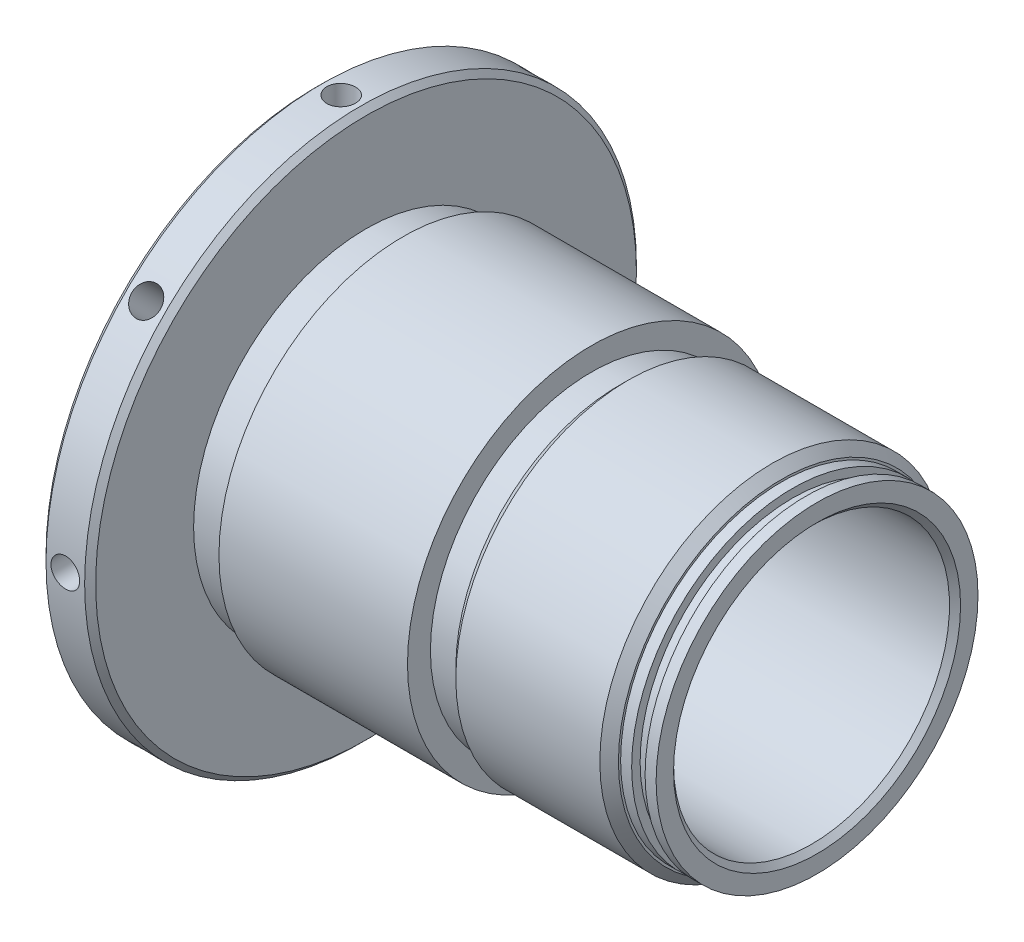
from build123d import *

# Parameters (mm, degrees)
CHAMFER1_SIZE      = 0.762
SKETCH3_W          = 6.858
SKETCH3_H          = 18.542
SKETCH5_W          = 5.08
SKETCH5_H          = 1.58115
CHAMFER3_SIZE      = 0.762
SKETCH6_R          = 1.9812
CUT_EXTRUDE2_DEPTH = 6.35
CHAMFER4_SIZE      = 1.2827
CIRPATTERN2_COUNT  = 8
SKETCH7_W          = 1.524
SKETCH7_H          = 0.4064
EXTRUDE1_DEPTH     = 0.0254


with BuildPart() as part:
    # Sketch1 → Revolve1 (revolve)
    with BuildSketch(Plane.XY, mode=Mode.PRIVATE) as revolve1_sk:
        Polygon((0, 19.558), (0, 25.39365), (62.2808, 25.39365), (62.2808, 19.05635), (22.09165, 19.05635), (20.828, 20.32), (17.78, 20.32), (17.018, 19.558), align=None)
    revolve(revolve1_sk.sketch.rotate(Axis((0, 0, 0), (1, 0, 0)), 90), axis=Axis((0, 0, 0), (1, 0, 0)))  # turned: the seam where the file's is

    # Sketch2 → Cut-Revolve1 (revolve, cut)
    with BuildSketch(Plane.XY, mode=Mode.PRIVATE) as cut_revolve1_sk:
        Polygon((31.115, 25.39365), (62.2808, 25.39365), (62.2808, 22.225), (60.7568, 22.225), (60.7568, 21.0566), (58.9026, 21.0566), (58.9026, 22.225), (57.3786, 22.225), (57.3786, 23.8125), (34.925, 23.8125), (34.925, 22.225), (31.115, 22.225), align=None)
    revolve(cut_revolve1_sk.sketch.rotate(Axis((0, 0, 0), (1, 0, 0)), 90), axis=Axis((0, 0, 0), (1, 0, 0)), mode=Mode.SUBTRACT)  # turned: the seam where the file's is

    # Chamfer1
    chamfer1_edges = [part.edges().sort_by_distance(p)[0] for p in [
        (62.2808, 0, -19.05635),
    ]]
    chamfer(chamfer1_edges, length=CHAMFER1_SIZE)

    # Sketch3 → Revolve2 (revolve)
    with BuildSketch(Plane.XY, mode=Mode.PRIVATE) as revolve2_sk:
        with Locations((-3.429, 28.829)):
            Rectangle(SKETCH3_W, SKETCH3_H)
    revolve(revolve2_sk.sketch.rotate(Axis((0, 0, 0), (-1, 0, 0)), 270), axis=Axis((0, 0, 0), (-1, 0, 0)))  # turned: the seam where the file's is

    # Sketch5 → Cut-Revolve2 (revolve, cut)
    with BuildSketch(Plane.XY, mode=Mode.PRIVATE) as cut_revolve2_sk:
        with Locations((2.54, 24.603075)):
            Rectangle(SKETCH5_W, SKETCH5_H)
    revolve(cut_revolve2_sk.sketch.rotate(Axis((23.353313309, 0, 0), (1, 0, 0)), 90), axis=Axis((23.353313309, 0, 0), (1, 0, 0)), mode=Mode.SUBTRACT)  # turned: the seam where the file's is

    # Chamfer3
    chamfer3_edges = [part.edges().sort_by_distance(p)[0] for p in [
        (0, 0, -38.1),
        (-6.858, 0, -38.1),
    ]]
    chamfer(chamfer3_edges, length=CHAMFER3_SIZE)

    # Sketch6 → Cut-Extrude2 (cut)
    with BuildSketch(Plane(origin=(-3.429, 38.1, 0), x_dir=(0, 0, 1), z_dir=(0, 1, 0))):
        Circle(SKETCH6_R)
    cut_extrude2 = extrude(amount=-CUT_EXTRUDE2_DEPTH, mode=Mode.SUBTRACT)

    # Chamfer4
    chamfer4_edges = [part.edges().sort_by_distance(p)[0] for p in [
        (34.925, 0, -23.8125),
        (57.3786, 0, -23.8125),
    ]]
    chamfer(chamfer4_edges, length=CHAMFER4_SIZE)

    # CirPattern2: Cut-Extrude2 ×8 about axis
    cirpattern2_axis = Axis((0, 0, 0), (1, 0, 0))
    for i in range(1, CIRPATTERN2_COUNT):
        add(cut_extrude2.rotate(cirpattern2_axis, i * 360 / CIRPATTERN2_COUNT), mode=Mode.SUBTRACT)

    # Sketch7 → Extrude1 (cut)
    with BuildSketch(Plane.ZY.offset(6.858)):
        with BuildLine():
            Line((-9.4996, 27.070692568), (-9.1646375, 27.271511318))
            add(Edge.make_bspline(
                [(-9.1646375, 27.271511318), (-9.13348371, 27.21936117), (-9.073794252, 27.119443498), (-8.974223262, 26.984429767), (-8.871050391, 26.869676221), (-8.76351161, 26.77585043), (-8.652263326, 26.701981233), (-8.536579299, 26.649675027), (-8.416849371, 26.617052049), (-8.335366779, 26.613089551), (-8.2946875, 26.611111318)],
                knots=[0, 0, 0, 0, 1.272034388, 2.437168799, 3.508375237, 4.49857839, 5.41946034, 6.295179144, 7.148887113, 8, 8, 8, 8], degree=3))
            add(Edge.make_bspline(
                [(-8.2946875, 26.611111318), (-8.259946467, 26.612078905), (-8.191072287, 26.613997148), (-8.089677592, 26.632428877), (-7.991204251, 26.660745465), (-7.897681832, 26.701298854), (-7.810400786, 26.750362973), (-7.73386228, 26.809624828), (-7.667694601, 26.875973751), (-7.613569219, 26.949994388), (-7.572043227, 27.029601436), (-7.540126584, 27.111312862), (-7.522414572, 27.196412272), (-7.519746458, 27.2537091), (-7.5184, 27.282623818)],
                knots=[0, 0, 0, 0, 1.095163259, 2.171163733, 3.241058638, 4.321873601, 5.38011039, 6.391990106, 7.366004449, 8.327778327, 9.272591725, 10.192022065, 11.087607919, 12, 12, 12, 12], degree=3))
            add(Edge.make_bspline(
                [(-7.5184, 27.282623818), (-7.520069088, 27.31561459), (-7.523462101, 27.382680009), (-7.552140231, 27.481626405), (-7.597254133, 27.579545879), (-7.638873647, 27.640115426), (-7.66048125, 27.671561318)],
                knots=[0, 0, 0, 0, 0.938893495, 1.908633276, 2.914225137, 4, 4, 4, 4], degree=3))
            add(Edge.make_bspline(
                [(-7.66048125, 27.671561318), (-7.678222176, 27.694256613), (-7.715467032, 27.741902547), (-7.7794966, 27.812824113), (-7.854630626, 27.885979548), (-7.938297896, 27.964162293), (-8.033546168, 28.043736112), (-8.137392197, 28.128495559), (-8.252487304, 28.215217299), (-8.333206483, 28.273376914), (-8.37485625, 28.303386318)],
                knots=[0, 0, 0, 0, 0.722233717, 1.516239348, 2.393582979, 3.351407094, 4.387010283, 5.505090956, 6.712668013, 8, 8, 8, 8], degree=3))
            add(Edge.make_bspline(
                [(-8.37485625, 28.303386318), (-8.416545222, 28.333080077), (-8.496251362, 28.389852282), (-8.60771773, 28.474109077), (-8.707394124, 28.551142514), (-8.794837518, 28.621677776), (-8.87000945, 28.68572443), (-8.933502281, 28.742667446), (-8.983698595, 28.794046823), (-9.01161153, 28.827377787), (-9.02414375, 28.842342568)],
                knots=[0, 0, 0, 0, 1.452282411, 2.77665338, 3.964542531, 5.026858415, 5.96415736, 6.766646006, 7.446254459, 8, 8, 8, 8], degree=3))
            add(Edge.make_bspline(
                [(-9.02414375, 28.842342568), (-9.041660439, 28.865665296), (-9.07610936, 28.911532571), (-9.121581869, 28.983223547), (-9.160231303, 29.056610892), (-9.190529321, 29.13189181), (-9.216042897, 29.208009434), (-9.233203406, 29.285956913), (-9.243948753, 29.365384487), (-9.245049152, 29.418835565), (-9.2456, 29.445592568)],
                knots=[0, 0, 0, 0, 1.068054152, 2.10047183, 3.106115577, 4.101338837, 5.06977816, 6.043150881, 7.020423561, 8, 8, 8, 8], degree=3))
            add(Edge.make_bspline(
                [(-9.2456, 29.445592568), (-9.244122354, 29.487514505), (-9.241198646, 29.570462326), (-9.216472685, 29.691633459), (-9.177445429, 29.807320161), (-9.122770097, 29.916377108), (-9.052287658, 30.015964652), (-8.970723382, 30.107228332), (-8.873574972, 30.183950112), (-8.766983442, 30.250984929), (-8.650311851, 30.303453813), (-8.528053807, 30.343033639), (-8.400014996, 30.365459982), (-8.313291493, 30.368678317), (-8.2692875, 30.370311318)],
                knots=[0, 0, 0, 0, 1.005424448, 1.989358655, 2.955360095, 3.929531133, 4.905563448, 5.876582895, 6.856512386, 7.866279853, 8.892233794, 9.918561126, 10.94386622, 12, 12, 12, 12], degree=3))
            add(Edge.make_bspline(
                [(-8.2692875, 30.370311318), (-8.222594465, 30.368700827), (-8.129736921, 30.365498075), (-7.99314822, 30.337650858), (-7.861641014, 30.291573046), (-7.755852559, 30.239282206), (-7.673057915, 30.187056172), (-7.609916807, 30.139484928), (-7.545932594, 30.084718777), (-7.48058916, 30.022611841), (-7.414993711, 29.95259425), (-7.348172418, 29.875145532), (-7.27996902, 29.79073899), (-7.236092958, 29.730482772), (-7.2136, 29.699592568)],
                knots=[0, 0, 0, 0, 1.286793592, 2.559021753, 3.825965368, 5.121522368, 5.803751409, 6.523245864, 7.299691795, 8.125521123, 9.008227632, 9.944561021, 10.946284179, 12, 12, 12, 12], degree=3))
            Line((-7.2136, 29.699592568), (-7.53506875, 29.455911318))
            add(Edge.make_bspline(
                [(-7.53506875, 29.455911318), (-7.554479905, 29.48091824), (-7.591861251, 29.529075725), (-7.64861356, 29.596517262), (-7.702104429, 29.658122936), (-7.754804801, 29.711632463), (-7.803931352, 29.759976158), (-7.851612657, 29.801365981), (-7.897162541, 29.836207472), (-7.95457988, 29.873390136), (-8.026715619, 29.910247818), (-8.117267255, 29.941436523), (-8.211896471, 29.960178745), (-8.27634732, 29.962656816), (-8.308975, 29.963911318)],
                knots=[0, 0, 0, 0, 1.181633172, 2.275549214, 3.290209073, 4.226197932, 5.078386478, 5.862611352, 6.581680152, 7.217281963, 8.414376989, 9.595101626, 10.782541182, 12, 12, 12, 12], degree=3))
            add(Edge.make_bspline(
                [(-8.308975, 29.963911318), (-8.349908316, 29.962539535), (-8.428844359, 29.959894181), (-8.540912619, 29.931002641), (-8.641777124, 29.885512183), (-8.728443377, 29.821757192), (-8.800600919, 29.746221403), (-8.852797568, 29.659298964), (-8.884213925, 29.563315595), (-8.888047581, 29.496360481), (-8.89, 29.462261318)],
                knots=[0, 0, 0, 0, 1.14458467, 2.207223713, 3.21896685, 4.227309161, 5.202851033, 6.127160689, 7.046193047, 8, 8, 8, 8], degree=3))
            add(Edge.make_bspline(
                [(-8.89, 29.462261318), (-8.889554936, 29.441032501), (-8.888664079, 29.398540155), (-8.876239354, 29.335762808), (-8.860277302, 29.27314405), (-8.83498289, 29.210965409), (-8.800062481, 29.148139453), (-8.754205993, 29.083584329), (-8.696453093, 29.016731046), (-8.652213449, 28.97324951), (-8.62885625, 28.950292568)],
                knots=[0, 0, 0, 0, 0.858281714, 1.717966888, 2.583508476, 3.4729293, 4.427298488, 5.488583878, 6.674047936, 8, 8, 8, 8], degree=3))
            add(Edge.make_bspline(
                [(-8.62885625, 28.950292568), (-8.620182701, 28.942552273), (-8.599576333, 28.924163105), (-8.561904183, 28.894057604), (-8.512155913, 28.856921117), (-8.451630591, 28.810971637), (-8.379212227, 28.757670041), (-8.294892858, 28.697697858), (-8.199612384, 28.629108194), (-8.13200035, 28.581154617), (-8.09625, 28.555798818)],
                knots=[0, 0, 0, 0, 0.420754252, 0.999615792, 1.744751191, 2.668019286, 3.750313428, 4.999500688, 6.413464383, 8, 8, 8, 8], degree=3))
            add(Edge.make_bspline(
                [(-8.09625, 28.555798818), (-8.053245605, 28.52450564), (-7.969973554, 28.463910738), (-7.851489213, 28.372870998), (-7.744058577, 28.283832735), (-7.647304463, 28.197364555), (-7.560271017, 28.114122351), (-7.48392381, 28.033104652), (-7.417484913, 27.954891888), (-7.345958817, 27.85461761), (-7.272871987, 27.731464991), (-7.210105865, 27.580578793), (-7.17052902, 27.429106067), (-7.165353542, 27.327298611), (-7.1628, 27.277067568)],
                knots=[0, 0, 0, 0, 1.163667725, 2.253281268, 3.268753668, 4.215851969, 5.092017293, 5.902905408, 6.650798638, 7.335211899, 8.59617414, 9.77448103, 10.901945474, 12, 12, 12, 12], degree=3))
            add(Edge.make_bspline(
                [(-7.1628, 27.277067568), (-7.163543955, 27.241543673), (-7.165017419, 27.171185732), (-7.181954883, 27.067874556), (-7.20677045, 26.967534282), (-7.244172374, 26.871405199), (-7.289822798, 26.777728671), (-7.347748838, 26.688961967), (-7.414891915, 26.60314046), (-7.491913912, 26.522552612), (-7.576195182, 26.44857325), (-7.665274116, 26.382764509), (-7.759296517, 26.327892828), (-7.857752326, 26.283116755), (-7.96066416, 26.248096478), (-8.067997407, 26.222722548), (-8.179928993, 26.207149512), (-8.256007618, 26.205533122), (-8.2946875, 26.204711318)],
                knots=[0, 0, 0, 0, 0.983748083, 1.948392443, 2.894712957, 3.844097841, 4.80183111, 5.778335162, 6.776009319, 7.81870978, 8.863265674, 9.881300176, 10.883814829, 11.87499822, 12.874611388, 13.892143829, 14.928324115, 16, 16, 16, 16], degree=3))
            add(Edge.make_bspline(
                [(-8.2946875, 26.204711318), (-8.324615329, 26.205290034), (-8.384094078, 26.206440178), (-8.472070093, 26.216608014), (-8.558268809, 26.230993907), (-8.64160859, 26.25383326), (-8.723163172, 26.281543995), (-8.802577859, 26.315664032), (-8.879891136, 26.356552832), (-8.955536277, 26.403303519), (-9.029320891, 26.457710378), (-9.100552919, 26.521078773), (-9.171569526, 26.59166101), (-9.240274595, 26.671373815), (-9.308057837, 26.758929363), (-9.373582811, 26.855146832), (-9.438205839, 26.959502131), (-9.478753042, 27.032936821), (-9.4996, 27.070692568)],
                knots=[0, 0, 0, 0, 0.915332311, 1.819136955, 2.706846663, 3.586547465, 4.459518054, 5.340707479, 6.227863349, 7.133153174, 8.059268498, 9.028702269, 10.047606654, 11.120612155, 12.245963614, 13.433783089, 14.680604001, 16, 16, 16, 16], degree=3))
        make_face()
        Polygon((-6.8072, 29.862311318), (-6.8072, 30.268711318), (-4.7244, 30.268711318), (-4.7244, 29.862311318), (-5.588, 29.862311318), (-5.588, 26.306311318), (-5.9436, 26.306311318), (-5.9436, 29.862311318), align=None)
        with BuildLine():
            Line((-0.4064, 29.592436318), (-0.7112, 29.303511318))
            add(Edge.make_bspline(
                [(-0.7112, 29.303511318), (-0.766355349, 29.355397093), (-0.875350837, 29.457931396), (-1.05304777, 29.590967273), (-1.238446919, 29.704932803), (-1.430580862, 29.797660023), (-1.62469154, 29.871646817), (-1.818202449, 29.924321989), (-2.009128657, 29.957914693), (-2.136114767, 29.961931852), (-2.1986875, 29.963911318)],
                knots=[0, 0, 0, 0, 1.08915593, 2.152340314, 3.188132944, 4.216796309, 5.218260357, 6.173443236, 7.099959455, 8, 8, 8, 8], degree=3))
            add(Edge.make_bspline(
                [(-2.1986875, 29.963911318), (-2.237082816, 29.963443069), (-2.313773869, 29.962507785), (-2.427689409, 29.950570528), (-2.540410221, 29.933402169), (-2.651723519, 29.908561456), (-2.761845731, 29.877078422), (-2.870393859, 29.837697302), (-2.977570388, 29.791784131), (-3.082365771, 29.738730455), (-3.183962277, 29.680449386), (-3.279916701, 29.615863918), (-3.370840648, 29.54704406), (-3.455025147, 29.472266803), (-3.532954446, 29.392209494), (-3.606483425, 29.308361367), (-3.673026042, 29.218431621), (-3.733131308, 29.124074847), (-3.786750073, 29.026948284), (-3.834082247, 28.92798679), (-3.873816162, 28.827518604), (-3.905254359, 28.725417658), (-3.931191837, 28.622473838), (-3.94943881, 28.517974345), (-3.959726018, 28.411807288), (-3.961505453, 28.340713614), (-3.9624, 28.304973818)],
                knots=[0, 0, 0, 0, 1.02818874, 2.053710826, 3.065248034, 4.081641283, 5.106893873, 6.131558223, 7.173050175, 8.228653731, 9.27666206, 10.308777013, 11.325269123, 12.329503258, 13.32196095, 14.316845687, 15.314881793, 16.315733098, 17.311955233, 18.285320748, 19.252783886, 20.203351036, 21.145449891, 22.095197417, 23.042428769, 24, 24, 24, 24], degree=3))
            add(Edge.make_bspline(
                [(-3.9624, 28.304973818), (-3.961544441, 28.268439565), (-3.959835658, 28.195470821), (-3.948899072, 28.086568138), (-3.928602255, 27.979282872), (-3.901468069, 27.873262482), (-3.86752636, 27.768325397), (-3.825216231, 27.664926557), (-3.775102512, 27.563069792), (-3.717096879, 27.463672856), (-3.653487676, 27.366851019), (-3.582228915, 27.275648434), (-3.506535093, 27.188850616), (-3.423648591, 27.108384728), (-3.336227244, 27.032098457), (-3.241659161, 26.962093579), (-3.141803896, 26.897021661), (-3.036509102, 26.837702813), (-2.926917289, 26.784710201), (-2.814547301, 26.737587194), (-2.699040154, 26.698779066), (-2.581002873, 26.66714994), (-2.460576173, 26.641224186), (-2.337148768, 26.624545335), (-2.211628191, 26.612442092), (-2.127015518, 26.611557152), (-2.0843875, 26.611111318)],
                knots=[0, 0, 0, 0, 0.93586088, 1.869166235, 2.799637598, 3.729985548, 4.670839027, 5.622275134, 6.589130586, 7.576015415, 8.568469353, 9.55398029, 10.53834874, 11.515998671, 12.510579167, 13.508179873, 14.527009472, 15.561807829, 16.601455013, 17.643573243, 18.680854198, 19.719860599, 20.772568776, 21.833555941, 22.908541556, 24, 24, 24, 24], degree=3))
            add(Edge.make_bspline(
                [(-2.0843875, 26.611111318), (-2.033014025, 26.612185215), (-1.93213386, 26.614293986), (-1.783842237, 26.63070997), (-1.641418783, 26.656348729), (-1.505263696, 26.693896315), (-1.375218837, 26.741788909), (-1.250807468, 26.799521515), (-1.133009099, 26.869308503), (-1.021469607, 26.948074071), (-0.918722101, 27.035829721), (-0.826053877, 27.130524803), (-0.744942996, 27.231699668), (-0.674180533, 27.338758413), (-0.615640426, 27.452587189), (-0.567590332, 27.572628167), (-0.530758928, 27.698935342), (-0.51563957, 27.786211879), (-0.508, 27.830311318)],
                knots=[0, 0, 0, 0, 1.13008108, 2.219097802, 3.278683437, 4.311054135, 5.322181354, 6.324827112, 7.324222904, 8.330512327, 9.32562643, 10.293043162, 11.24128371, 12.174520618, 13.111833804, 14.052305215, 15.015860969, 16, 16, 16, 16], degree=3))
            Line((-0.508, 27.830311318), (-1.8288, 27.830311318))
            Line((-1.8288, 27.830311318), (-1.8288, 28.236711318))
            Line((-1.8288, 28.236711318), (-0.1524, 28.236711318))
            add(Edge.make_bspline(
                [(-0.1524, 28.236711318), (-0.154331215, 28.160964394), (-0.158110953, 28.012713981), (-0.184623842, 27.796513809), (-0.227436455, 27.592312439), (-0.285921832, 27.399894817), (-0.361632293, 27.219533623), (-0.453755294, 27.051045734), (-0.563765241, 26.895519631), (-0.687743576, 26.751685639), (-0.826880374, 26.623384019), (-0.977416048, 26.510618713), (-1.139599309, 26.415631364), (-1.313276743, 26.338352493), (-1.497879789, 26.278040242), (-1.693835617, 26.235278501), (-1.90087849, 26.209658796), (-2.042773932, 26.206385424), (-2.11534375, 26.204711318)],
                knots=[0, 0, 0, 0, 1.140356446, 2.231883559, 3.274166699, 4.278491846, 5.25512956, 6.21435461, 7.1637429, 8.11826594, 9.068280886, 10.0076534, 10.945064095, 11.891975133, 12.864533718, 13.863980011, 14.907571808, 16, 16, 16, 16], degree=3))
            add(Edge.make_bspline(
                [(-2.11534375, 26.204711318), (-2.160073739, 26.205355628), (-2.248295693, 26.206626416), (-2.378591776, 26.215657685), (-2.505295313, 26.229560701), (-2.628387846, 26.2505559), (-2.748322156, 26.276271484), (-2.864499254, 26.309200974), (-2.9773617, 26.34731779), (-3.087083936, 26.390672869), (-3.192670061, 26.440906655), (-3.294590367, 26.496730802), (-3.393408237, 26.557857458), (-3.48845055, 26.625343748), (-3.580212513, 26.698684896), (-3.668102444, 26.778027902), (-3.752612373, 26.863130201), (-3.805550562, 26.92356134), (-3.832225, 26.954011318)],
                knots=[0, 0, 0, 0, 1.107784379, 2.184907829, 3.233506516, 4.263428166, 5.276301166, 6.270063455, 7.25232949, 8.225834625, 9.190232166, 10.146266622, 11.1027726, 12.066435141, 13.031522626, 14.010570082, 14.99756817, 16, 16, 16, 16], degree=3))
            add(Edge.make_bspline(
                [(-3.832225, 26.954011318), (-3.870927382, 27.002319374), (-3.947689726, 27.098133622), (-4.046498574, 27.251648256), (-4.130729465, 27.410599208), (-4.199072739, 27.575428966), (-4.25243844, 27.745983356), (-4.290710982, 27.922044439), (-4.313135097, 28.103838933), (-4.316365627, 28.226860432), (-4.318, 28.289098818)],
                knots=[0, 0, 0, 0, 1.023165419, 2.029347347, 3.013907458, 3.994755782, 4.975994455, 5.96558838, 6.970761222, 8, 8, 8, 8], degree=3))
            add(Edge.make_bspline(
                [(-4.318, 28.289098818), (-4.317397446, 28.335703721), (-4.316199995, 28.428321206), (-4.301680045, 28.565824759), (-4.280847537, 28.700886777), (-4.25022718, 28.833396856), (-4.211626311, 28.963443494), (-4.163450902, 29.091087074), (-4.107360417, 29.216402923), (-4.042167055, 29.33852847), (-3.969616123, 29.455843148), (-3.890877325, 29.567874691), (-3.804832563, 29.672582883), (-3.712886996, 29.771293794), (-3.613943615, 29.862767323), (-3.508929346, 29.947850365), (-3.39776326, 30.026657051), (-3.280095626, 30.0979461), (-3.15768273, 30.161982583), (-3.030818001, 30.218123238), (-2.899540167, 30.264521035), (-2.764832744, 30.303888928), (-2.625676086, 30.333001406), (-2.483080023, 30.354113917), (-2.336301279, 30.368560374), (-2.237087278, 30.369722213), (-2.18678125, 30.370311318)],
                knots=[0, 0, 0, 0, 1.008945113, 2.00506715, 2.99143336, 3.967273523, 4.948097931, 5.927297278, 6.919902385, 7.919676788, 8.923139349, 9.905703106, 10.883022732, 11.856032218, 12.825136022, 13.798837087, 14.781400844, 15.773989409, 16.776158564, 17.77167057, 18.775803737, 19.789618931, 20.80898985, 21.851988756, 22.910860228, 24, 24, 24, 24], degree=3))
            add(Edge.make_bspline(
                [(-2.18678125, 30.370311318), (-2.145755417, 30.369655267), (-2.06440601, 30.368354395), (-1.943353861, 30.359337504), (-1.824172777, 30.345045827), (-1.706686044, 30.325543136), (-1.591293749, 30.298979557), (-1.477667168, 30.26719173), (-1.365641588, 30.23018085), (-1.255568098, 30.18604102), (-1.146706574, 30.13594086), (-1.038451722, 30.079546372), (-0.931173426, 30.015893241), (-0.824685645, 29.944792462), (-0.718316876, 29.867465187), (-0.613749545, 29.781699804), (-0.508459583, 29.690878476), (-0.440757095, 29.625575652), (-0.4064, 29.592436318)],
                knots=[0, 0, 0, 0, 0.985871117, 1.954866573, 2.915460327, 3.869826059, 4.81536089, 5.759505086, 6.70452669, 7.649098992, 8.607881297, 9.583363685, 10.581137262, 11.603961102, 12.659522466, 13.73993555, 14.853081303, 16, 16, 16, 16], degree=3))
        make_face()
        with BuildLine():
            add(Edge.make_bspline(
                [(1.8288, 28.285923818), (1.829171354, 28.349432472), (1.829892715, 28.472798948), (1.837917617, 28.65256131), (1.85124865, 28.821201381), (1.869518001, 28.978727234), (1.891750439, 29.125179535), (1.921429366, 29.260166907), (1.955180865, 29.384314114), (1.994298183, 29.498025992), (2.038436816, 29.602834532), (2.086477249, 29.700677738), (2.140326032, 29.791407564), (2.196905609, 29.87647213), (2.258506293, 29.954478987), (2.323375072, 30.026529755), (2.39404377, 30.090959228), (2.468110092, 30.149655168), (2.546244617, 30.201109164), (2.626220189, 30.246430799), (2.708587283, 30.285148957), (2.793570781, 30.315592004), (2.880406843, 30.340737221), (2.969399026, 30.357932846), (3.060694266, 30.368752358), (3.122316871, 30.369786735), (3.15356875, 30.370311318)],
                knots=[0, 0, 0, 0, 1.646270934, 3.197905019, 4.663502075, 6.030701355, 7.308322542, 8.50163776, 9.611534131, 10.641858119, 11.616356847, 12.558055219, 13.465016945, 14.349605745, 15.204443733, 16.039544428, 16.859896111, 17.680448484, 18.487036065, 19.28249412, 20.06191084, 20.843045899, 21.620316918, 22.403196591, 23.190181807, 24, 24, 24, 24], degree=3))
            add(Edge.make_bspline(
                [(3.15356875, 30.370311318), (3.185081693, 30.369759056), (3.247751021, 30.368660779), (3.340403679, 30.358105011), (3.430915856, 30.340589931), (3.518901671, 30.315772883), (3.605083856, 30.284984269), (3.688788319, 30.246393756), (3.770534988, 30.201472744), (3.849024797, 30.148689186), (3.925119423, 30.089839309), (3.996949768, 30.023313252), (4.064522371, 29.949782747), (4.128685294, 29.870034506), (4.187618179, 29.782538958), (4.24374097, 29.688817884), (4.293975186, 29.587232291), (4.342355722, 29.479477123), (4.384116006, 29.36257086), (4.421777198, 29.237172492), (4.452207262, 29.101800847), (4.477554477, 28.957166177), (4.497190882, 28.802737316), (4.511492476, 28.638845302), (4.519047171, 28.465382309), (4.520469901, 28.346784452), (4.5212, 28.285923818)],
                knots=[0, 0, 0, 0, 0.810914788, 1.612654377, 2.396697861, 3.181598691, 3.963628158, 4.749916497, 5.551656086, 6.361998678, 7.18212741, 8.025565596, 8.878627764, 9.750805457, 10.657531673, 11.591944965, 12.560506719, 13.57287815, 14.630710178, 15.753379473, 16.941251878, 18.199788006, 19.531962791, 20.947069417, 22.433333509, 24, 24, 24, 24], degree=3))
            add(Edge.make_bspline(
                [(4.5212, 28.285923818), (4.520462332, 28.225328637), (4.519025015, 28.107261399), (4.511577168, 27.934578902), (4.496906516, 27.77155666), (4.478554957, 27.617803696), (4.453137901, 27.47395995), (4.421885698, 27.339527664), (4.387186029, 27.213926295), (4.344352719, 27.098184805), (4.297471062, 26.990688603), (4.246463431, 26.890307258), (4.191816471, 26.79615351), (4.132280001, 26.708980996), (4.068821132, 26.628172199), (4.000081655, 26.555153519), (3.927999276, 26.488165556), (3.851680717, 26.428557896), (3.771966794, 26.37638463), (3.690500895, 26.329725842), (3.605837559, 26.292102633), (3.519895421, 26.259797705), (3.431445181, 26.235117102), (3.340597096, 26.218051775), (3.24781327, 26.206083234), (3.185092367, 26.205170207), (3.15356875, 26.204711318)],
                knots=[0, 0, 0, 0, 1.561518951, 3.042555995, 4.452378317, 5.7783523, 7.031515105, 8.214008947, 9.334062868, 10.386615937, 11.391082383, 12.354592575, 13.286541444, 14.194233754, 15.072674879, 15.931287219, 16.775624067, 17.606195743, 18.42308326, 19.229000347, 20.022332153, 20.807536673, 21.593273796, 22.3848459, 23.188221202, 24, 24, 24, 24], degree=3))
            add(Edge.make_bspline(
                [(3.15356875, 26.204711318), (3.122317738, 26.205239286), (3.060696843, 26.206280335), (2.96938908, 26.217050966), (2.880764407, 26.234367224), (2.794385498, 26.258613267), (2.709809185, 26.288291458), (2.628187949, 26.326957331), (2.548614258, 26.371487993), (2.471300412, 26.422201529), (2.397699216, 26.48030354), (2.327396497, 26.544567202), (2.26215839, 26.616596175), (2.201438464, 26.695253124), (2.143729971, 26.779814411), (2.090645841, 26.871434578), (2.041545078, 26.969750338), (1.996664116, 27.075396878), (1.956871812, 27.189915817), (1.921722258, 27.314617275), (1.89396943, 27.450601903), (1.870214326, 27.596777519), (1.851053991, 27.753772256), (1.837973174, 27.921671346), (1.829888389, 28.100370162), (1.829169417, 28.222943921), (1.8288, 28.285923818)],
                knots=[0, 0, 0, 0, 0.810891512, 1.598919785, 2.382837074, 3.152667961, 3.926044502, 4.706494248, 5.493654104, 6.291793342, 7.103789334, 7.925228297, 8.761435821, 9.622817696, 10.50288917, 11.416980706, 12.369136599, 13.353924996, 14.394355917, 15.514179734, 16.714354668, 17.994756427, 19.357759367, 20.818452758, 22.365282078, 24, 24, 24, 24], degree=3))
        make_face()
        with BuildLine():
            add(Edge.make_bspline(
                [(2.1844, 28.287511318), (2.184535228, 28.234586448), (2.184797678, 28.131869668), (2.191653989, 27.982608029), (2.200994195, 27.843391563), (2.213041359, 27.714043502), (2.230932103, 27.595001671), (2.250978211, 27.48544733), (2.275373111, 27.385960255), (2.304236385, 27.295857758), (2.337111961, 27.213610709), (2.373006622, 27.137078408), (2.411567253, 27.065356776), (2.454722488, 26.999090041), (2.501722284, 26.938062103), (2.551505039, 26.881192796), (2.605928699, 26.830477493), (2.681218536, 26.769652553), (2.780614179, 26.706798549), (2.905849176, 26.65206525), (3.034534853, 26.617668837), (3.121878886, 26.613294624), (3.165475, 26.611111318)],
                knots=[0, 0, 0, 0, 1.459021318, 2.831673884, 4.118529203, 5.306027144, 6.411944654, 7.436330062, 8.375795394, 9.233974572, 10.042671642, 10.816086306, 11.563610507, 12.285937304, 12.993564865, 13.685989202, 14.367179055, 15.041617293, 16.353048772, 17.594441528, 18.799311195, 20, 20, 20, 20], degree=3))
            add(Edge.make_bspline(
                [(3.165475, 26.611111318), (3.209353114, 26.612920189), (3.297018749, 26.616534195), (3.425099135, 26.651401885), (3.549439553, 26.704010715), (3.646882826, 26.766217571), (3.721016549, 26.82545922), (3.774131944, 26.875968101), (3.822883104, 26.932523852), (3.869121, 26.993544015), (3.911528955, 27.060194395), (3.95009232, 27.132154495), (3.985282222, 27.209624144), (4.005330886, 27.263704949), (4.01558125, 27.291355068)],
                knots=[0, 0, 0, 0, 1.353760809, 2.704726607, 4.075137775, 5.516104923, 6.260822281, 7.007110065, 7.778089737, 8.566572457, 9.372053459, 10.217411131, 11.088608312, 12, 12, 12, 12], degree=3))
            add(Edge.make_bspline(
                [(4.01558125, 27.291355068), (4.027527057, 27.326710702), (4.051782168, 27.398497802), (4.083041853, 27.509856698), (4.10766013, 27.626694021), (4.129808095, 27.748311531), (4.144925281, 27.875606122), (4.157093034, 28.008183933), (4.164260095, 28.146144922), (4.165148523, 28.239878314), (4.1656, 28.287511318)],
                knots=[0, 0, 0, 0, 0.884706709, 1.796334032, 2.740027952, 3.714592787, 4.726048262, 5.777819803, 6.87074269, 8, 8, 8, 8], degree=3))
            add(Edge.make_bspline(
                [(4.1656, 28.287511318), (4.164977123, 28.335136618), (4.163758642, 28.428301885), (4.159101138, 28.564742239), (4.147074037, 28.694332827), (4.133716086, 28.817631929), (4.114020444, 28.933957014), (4.092784463, 29.044281897), (4.06425381, 29.147239795), (4.033777549, 29.244442654), (3.99889666, 29.334786115), (3.960500172, 29.418691391), (3.919493002, 29.49656356), (3.874953089, 29.568188969), (3.827409177, 29.63388844), (3.775606401, 29.692344702), (3.721599599, 29.745369502), (3.645954909, 29.805895241), (3.546924016, 29.86760871), (3.423698303, 29.924402083), (3.295462989, 29.957016363), (3.208773088, 29.961614657), (3.165475, 29.963911318)],
                knots=[0, 0, 0, 0, 1.31362396, 2.569729283, 3.763502607, 4.902122613, 5.988968491, 7.01645872, 7.998833611, 8.933434873, 9.825090667, 10.667526885, 11.477055099, 12.250526234, 12.991942729, 13.710640831, 14.402115721, 15.076753259, 16.378508321, 17.609869233, 18.806226677, 20, 20, 20, 20], degree=3))
            add(Edge.make_bspline(
                [(3.165475, 29.963911318), (3.121650186, 29.961611488), (3.033920719, 29.957007639), (2.904352554, 29.924523597), (2.780154691, 29.867903204), (2.681385673, 29.805690838), (2.605688225, 29.746437888), (2.552385235, 29.695055235), (2.502406723, 29.638850001), (2.456366238, 29.577260816), (2.413244817, 29.511071338), (2.373642313, 29.439760858), (2.337961093, 29.362968001), (2.305034075, 29.280757897), (2.276082756, 29.190663173), (2.252201979, 29.091298642), (2.230140408, 28.982092756), (2.214522587, 28.862406191), (2.200638614, 28.733025732), (2.191716027, 28.593461719), (2.184774743, 28.443949748), (2.184527416, 28.340701878), (2.1844, 28.287511318)],
                knots=[0, 0, 0, 0, 1.207732386, 2.417664972, 3.655092373, 4.956220595, 5.625982001, 6.301752483, 6.994047911, 7.697131622, 8.419323945, 9.170223765, 9.943494443, 10.752040957, 11.610060368, 12.549350801, 13.567764191, 14.679664412, 15.874934091, 17.154273443, 18.533957287, 20, 20, 20, 20], degree=3))
        make_face(mode=Mode.SUBTRACT)
        with Locations((5.6388, 27.830311318)):
            Rectangle(SKETCH7_W, SKETCH7_H)
        Polygon((7.54776875, 30.268711318), (8.2804, 30.268711318), (8.2804, 26.306311318), (7.9248, 26.306311318), (7.9248, 29.862311318), (7.3152, 29.862311318), align=None)
    extrude(amount=-EXTRUDE1_DEPTH, mode=Mode.SUBTRACT)


solid = part.part
